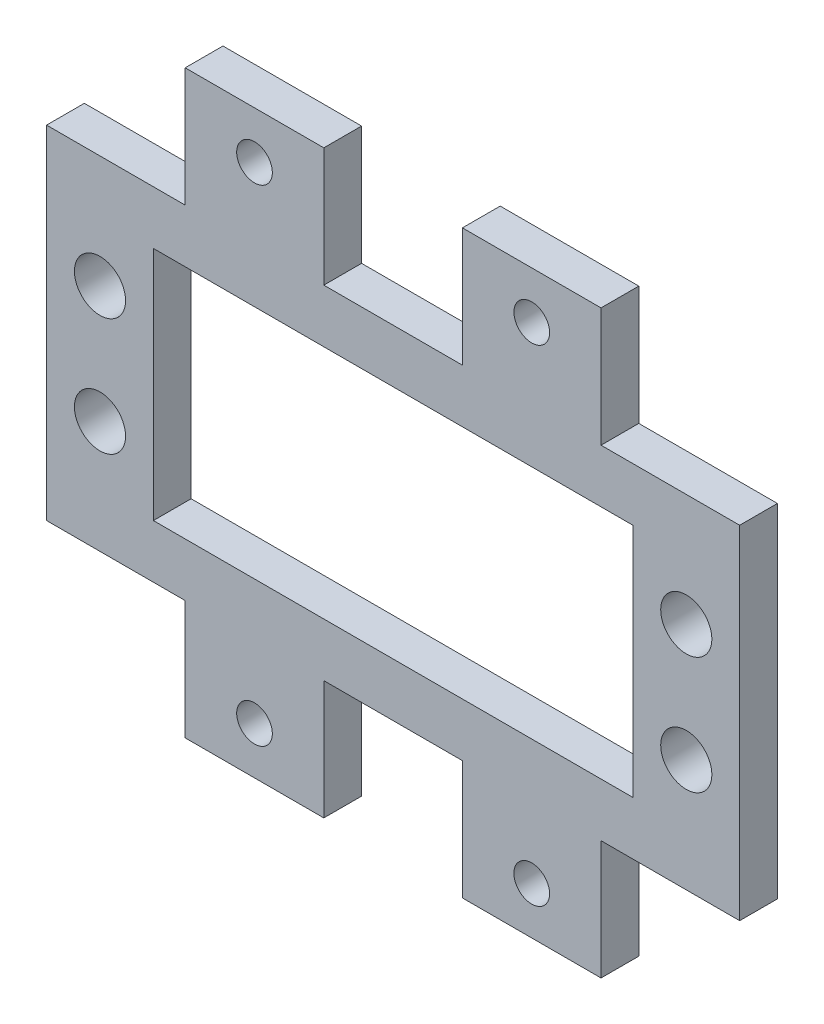
from build123d import *

# Parameters (mm, degrees)
SKETCH2_R           = 2.15
SKETCH2_R_2         = 1.5
BOSS_EXTRUDE1_DEPTH = 3.175


with BuildPart() as part:
    # Sketch2 → Boss-Extrude1 (new body)
    with BuildSketch(Plane.XY):
        Polygon((23.312, 14.4), (29.14, 14.4), (29.14, 9.91), (8.98, 9.91), (8.98, 0), (0, 0), (0, 14.4), (11.656, 14.4), (11.656, 24.4), (23.312, 24.4), align=None)
        with Locations((4.49, 4.935)):
            Circle(SKETCH2_R, mode=Mode.SUBTRACT)
        with Locations((17.484, 20.43125)):
            Circle(SKETCH2_R_2, mode=Mode.SUBTRACT)
    boss_extrude1 = extrude(amount=BOSS_EXTRUDE1_DEPTH)

    # Mirror8: Boss-Extrude1 across plane
    add(boss_extrude1.mirror(Plane(origin=(8.98, 0, 3.175), x_dir=(0, 0, 1), z_dir=(0, 1, 0))))

    # Mirror10: part across plane


with BuildPart() as part_1:
    add(part.part)
    add(part.part.mirror(Plane(origin=(29.14, 9.91, 3.175), x_dir=(0, 0, 1), z_dir=(-1, 0, 0))))


solid = part_1.part
